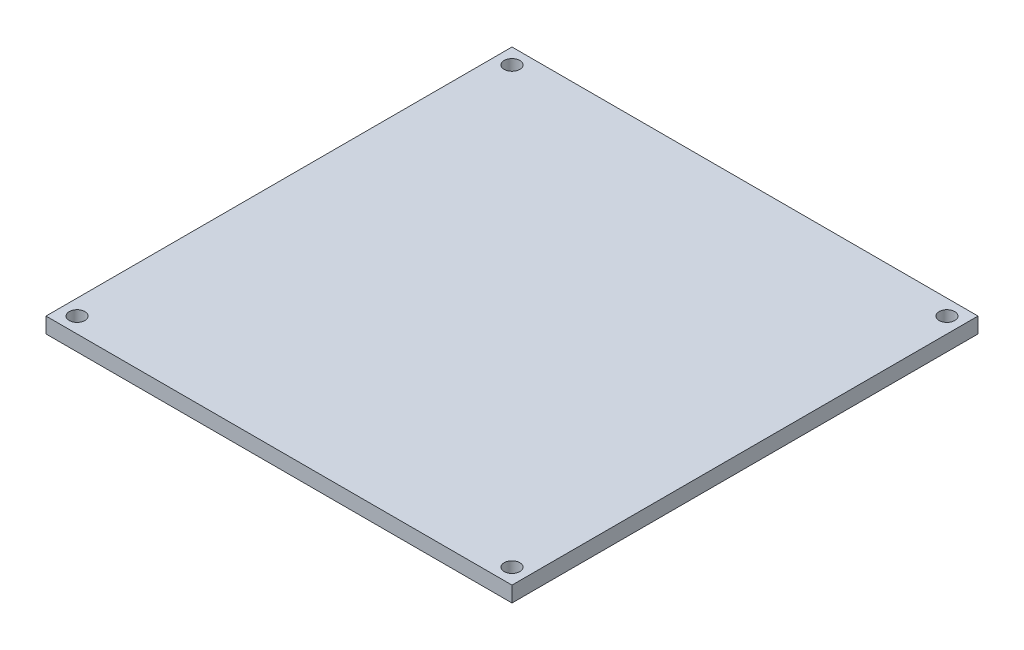
from build123d import *

# Parameters (mm, degrees)
SKETCH1_W           = 45
SKETCH1_H           = 45
SKETCH1_R           = 0.754054512
BOSS_EXTRUDE1_DEPTH = 1.5


with BuildPart() as part:
    # Sketch1 → Boss-Extrude1 (new body)
    with BuildSketch(Plane(origin=(0, 0, 0), x_dir=(1, 0, 0), z_dir=(0, 1, 0))):
        with Locations((22.5, 22.5)):
            Rectangle(SKETCH1_W, SKETCH1_H)
        with Locations((1.5, 1.5)):
            Circle(SKETCH1_R, mode=Mode.SUBTRACT)
        with Locations((1.5, 43.5)):
            Circle(SKETCH1_R, mode=Mode.SUBTRACT)
        with Locations((43.5, 43.5)):
            Circle(SKETCH1_R, mode=Mode.SUBTRACT)
        with Locations((43.5, 1.5)):
            Circle(SKETCH1_R, mode=Mode.SUBTRACT)
    extrude(amount=BOSS_EXTRUDE1_DEPTH)


solid = part.part
